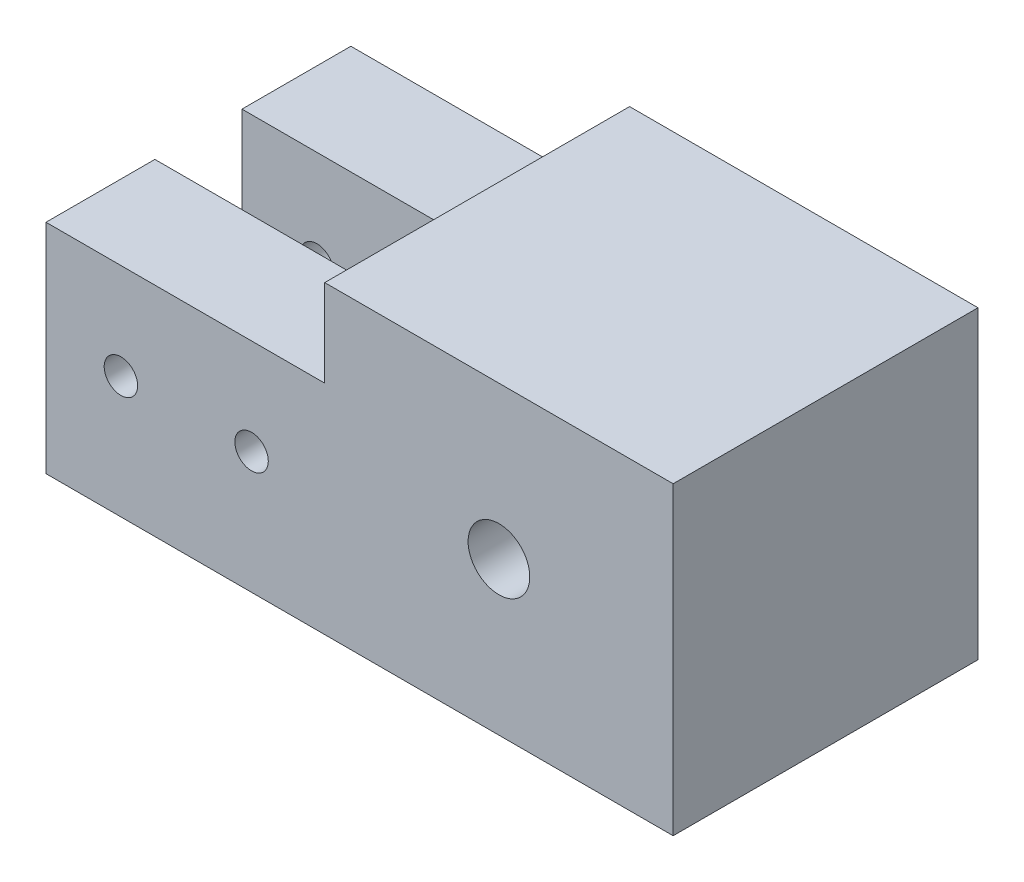
from build123d import *

# Parameters (mm, degrees)
SKETCH1_W             = 22.225
SKETCH1_H             = 22.225
BOSS_EXTRUDE1_DEPTH   = 25.4
F_8_CLEARANCE_HOLE1_D = 4.4958
BOSS_EXTRUDE2_DEPTH   = 20.32
F_2_CLEARANCE_HOLE1_D = 2.4384


with BuildPart() as part:
    # Sketch1 → Boss-Extrude1 (new body)
    with BuildSketch(Plane(origin=(0, 0, 0), x_dir=(0, 0, -1), z_dir=(1, 0, 0))):
        Rectangle(SKETCH1_W, SKETCH1_H)
    extrude(amount=BOSS_EXTRUDE1_DEPTH)

    # #8 Clearance Hole1 (through all)
    with Locations(Plane(origin=(12.7, 0, 11.1125), x_dir=(0, 1, 0), z_dir=(0, 0, 1))):
        with Locations((0, 0)):
            Hole(F_8_CLEARANCE_HOLE1_D / 2)

    # Sketch3 → Boss-Extrude2 (add)
    with BuildSketch(Plane.ZY):
        Polygon((-3.175, -11.1125), (-3.175, -4.7625), (-3.175, 4.7625), (-11.1125, 4.7625), (-11.1125, -11.1125), align=None)
        Polygon((3.175, 4.7625), (3.175, -4.7625), (3.175, -11.1125), (11.1125, -11.1125), (11.1125, 4.7625), align=None)
    extrude(amount=BOSS_EXTRUDE2_DEPTH)

    # #2 Clearance Hole1 (through all)
    with Locations(Plane(origin=(0, 0, -11.1125), x_dir=(-1, 0, 0), z_dir=(0, 0, -1))):
        with Locations((5.334, -2.2225), (14.859, -2.2225)):
            Hole(F_2_CLEARANCE_HOLE1_D / 2)


solid = part.part
